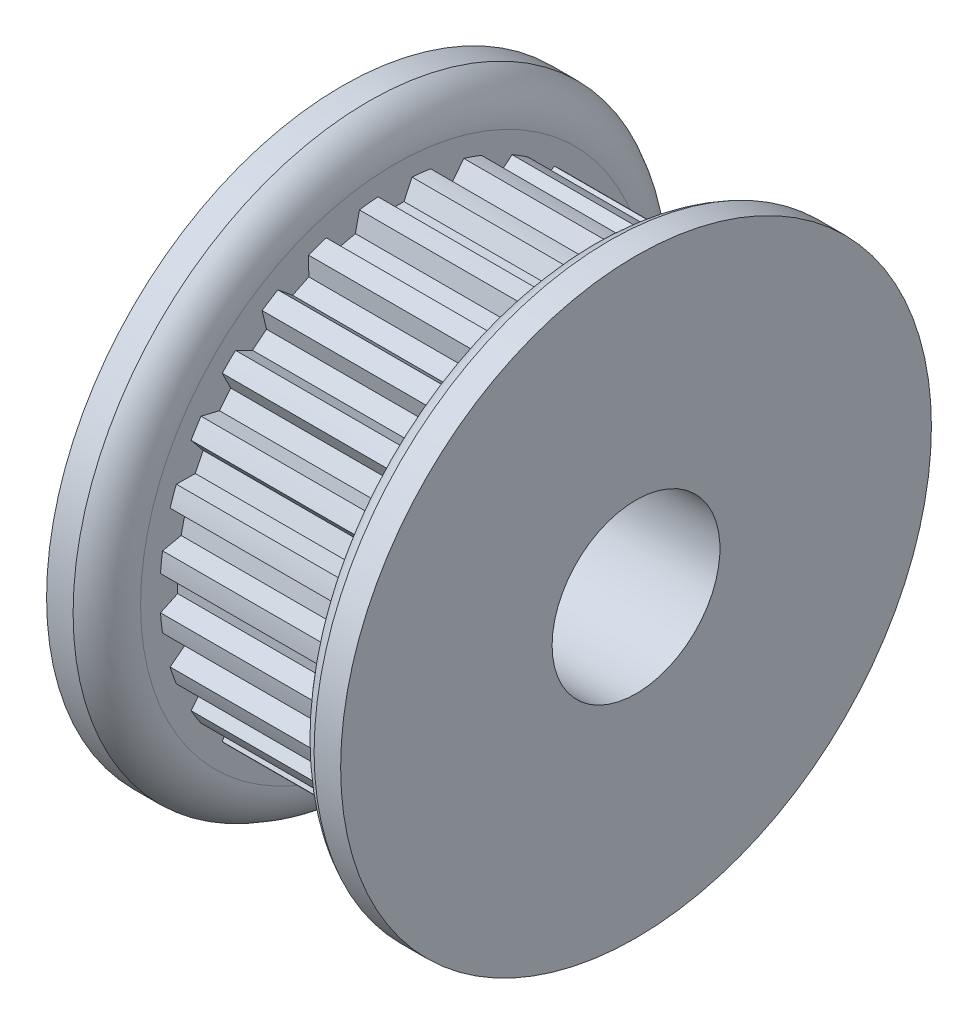
from build123d import *

# Parameters (mm, degrees)
SKETCH4_R          = 9.0551
SKETCH4_R_2        = 8.89635
CUT_EXTRUDE2_DEPTH = 7.112
CUT_EXTRUDE1_DEPTH = 7.112
CIRPATTERN1_COUNT  = 28
SKETCH6_R          = 8.7376
CUT_EXTRUDE3_DEPTH = 6.35


with BuildPart() as part:
    # Sketch1 → Revolve1 (revolve)
    with BuildSketch(Plane.XY, mode=Mode.PRIVATE) as revolve1_sk:
        with BuildLine():
            Line((-8.7376, 3.175), (8.7376, 3.175))
            Line((8.7376, 3.175), (8.7376, 11.176))
            Line((8.7376, 11.176), (7.7343, 11.176))
            ThreePointArc((7.7343, 11.176), (7.003726949, 10.549537058), (6.731, 9.6266))
            Line((6.731, 9.6266), (6.731, 9.0551))
            Line((6.731, 9.0551), (-0.381, 9.0551))
            Line((-0.381, 9.0551), (-0.381, 9.6266))
            ThreePointArc((-0.381, 9.6266), (-0.653726949, 10.549537058), (-1.3843, 11.176))
            Line((-1.3843, 11.176), (-2.3876, 11.176))
            Line((-2.3876, 11.176), (-2.3876, 8.7376))
            Line((-2.3876, 8.7376), (-8.7376, 8.7376))
            Line((-8.7376, 8.7376), (-8.7376, 3.175))
        make_face()
    revolve(revolve1_sk.sketch.rotate(Axis((-8.7376, 0, 0), (1, 0, 0)), 90), axis=Axis((-8.7376, 0, 0), (1, 0, 0)))

    # Sketch4 → Cut-Extrude2 (cut)
    with BuildSketch(Plane(origin=(-0.381, 0, 0), x_dir=(0, 0, -1), z_dir=(1, 0, 0))):
        Circle(SKETCH4_R)
        Circle(SKETCH4_R_2, mode=Mode.SUBTRACT)
    extrude(amount=CUT_EXTRUDE2_DEPTH, mode=Mode.SUBTRACT)

    # Sketch3 → Cut-Extrude1 (cut)
    with BuildSketch(Plane(origin=(-0.381, 0, 0), x_dir=(0, 0, -1), z_dir=(1, 0, 0))):
        with BuildLine():
            Line((-0.643388094, 8.873054439), (-0.340062676, 8.222570981))
            Line((-0.340062676, 8.222570981), (0.340062676, 8.222570981))
            Line((0.340062676, 8.222570981), (0.643388094, 8.873054439))
            ThreePointArc((0.643388094, 8.873054439), (0, 8.89635), (-0.643388094, 8.873054439))
        make_face()
    cut_extrude1 = extrude(amount=CUT_EXTRUDE1_DEPTH, mode=Mode.SUBTRACT)

    # CirPattern1: Cut-Extrude1 ×28 about axis
    cirpattern1_axis = Axis((0, 0, 0), (1, 0, 0))
    for i in range(1, CIRPATTERN1_COUNT):
        add(cut_extrude1.rotate(cirpattern1_axis, i * 360 / CIRPATTERN1_COUNT), mode=Mode.SUBTRACT)

    # Sketch6 → Cut-Extrude3 (cut)
    with BuildSketch(Plane.ZY.offset(8.7376)):
        Circle(SKETCH6_R)
    extrude(amount=-CUT_EXTRUDE3_DEPTH, mode=Mode.SUBTRACT)


solid = part.part
